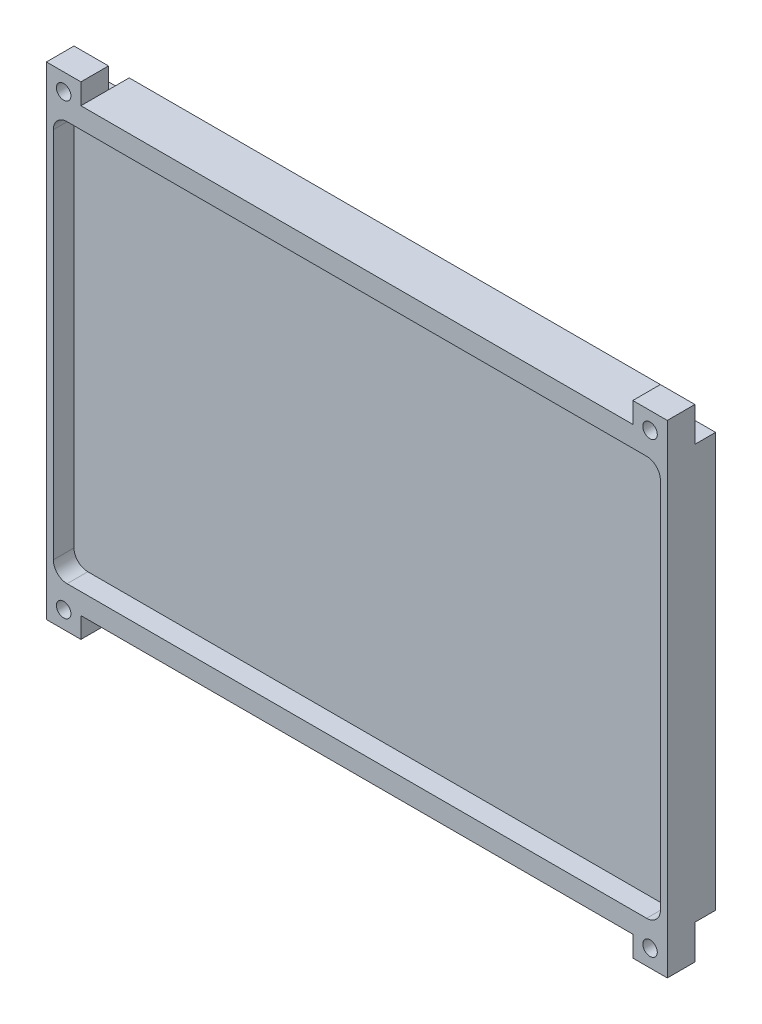
from build123d import *

# Parameters (mm, degrees)
SKETCH_1_W           = 100
SKETCH_1_H           = 70
EXTRUDE_1_DEPTH      = 10
SKETCH_6_W           = 5
SKETCH_6_H           = 5
CUT_EXTRUDE_4_DEPTH  = 5
SKETCH_7_W           = 5
SKETCH_7_H           = 5
CUT_EXTRUDE_5_DEPTH  = 3
SKETCH_8_R           = 1.05
CUT_EXTRUDE_6_DEPTH  = 42
SKETCH_10_W          = 100
SKETCH_10_H          = 70
CUT_EXTRUDE_7_DEPTH  = 3
SKETCH_11_W          = 7
SKETCH_11_H          = 70
CUT_EXTRUDE_8_DEPTH  = 5
SKETCH_12_W          = 7
SKETCH_12_H          = 70
CUT_EXTRUDE_9_DEPTH  = 5
SKETCH_15_W          = 82
SKETCH_15_H          = 52
CUT_EXTRUDE_12_DEPTH = 3
SKETCH_16_W          = 5
SKETCH_16_H          = 5
SKETCH_16_R          = 1.05
EXTRUDE_2_DEPTH      = 5
SKETCH_18_W          = 80
SKETCH_18_H          = 3
CUT_EXTRUDE_13_DEPTH = 10
SKETCH_19_W          = 82
SKETCH_19_H          = 52
CUT_EXTRUDE_14_DEPTH = 3
SKETCH_20_W          = 5
SKETCH_20_H          = 5
CUT_EXTRUDE_15_DEPTH = 3


with BuildPart() as part:
    # 草圖1 → 填料-伸長1 (new body)
    with BuildSketch(Plane.XY):
        with Locations((-39.08671555, 7.98136646)):
            Rectangle(SKETCH_1_W, SKETCH_1_H)
    extrude(amount=EXTRUDE_1_DEPTH)

    # 草圖6 → 除料-伸長4 (cut)
    with BuildSketch(Plane.XY.offset(10)):
        with Locations((3.41328445, 40.48136646)):
            Rectangle(SKETCH_6_W, SKETCH_6_H)
        with Locations((-81.58671555, 40.48136646)):
            Rectangle(SKETCH_6_W, SKETCH_6_H)
        with Locations((-81.58671555, -24.51863354)):
            Rectangle(SKETCH_6_W, SKETCH_6_H)
        with Locations((3.41328445, -24.51863354)):
            Rectangle(SKETCH_6_W, SKETCH_6_H)
    extrude(amount=-CUT_EXTRUDE_4_DEPTH, mode=Mode.SUBTRACT)

    # 草圖7 → 除料-伸長5 (cut)
    with BuildSketch(Plane(origin=(0, 0, 0), x_dir=(-1, 0, 0), z_dir=(0, 0, -1))):
        with Locations((81.58671555, 40.48136646)):
            Rectangle(SKETCH_7_W, SKETCH_7_H)
        with Locations((-3.41328445, 40.48136646)):
            Rectangle(SKETCH_7_W, SKETCH_7_H)
        with Locations((81.58671555, -24.51863354)):
            Rectangle(SKETCH_7_W, SKETCH_7_H)
        with Locations((-3.41328445, -24.51863354)):
            Rectangle(SKETCH_7_W, SKETCH_7_H)
    extrude(amount=-CUT_EXTRUDE_5_DEPTH, mode=Mode.SUBTRACT)

    # 草圖8 → 除料-伸長6 (cut)
    with BuildSketch(Plane(origin=(0, 0, 0), x_dir=(-1, 0, 0), z_dir=(0, 0, -1))):
        with Locations((-3.41328445, 40.48136646)):
            Circle(SKETCH_8_R)
        with Locations((81.58671555, 40.48136646)):
            Circle(SKETCH_8_R)
        with Locations((81.58671555, -24.51863354)):
            Circle(SKETCH_8_R)
        with Locations((-3.41328445, -24.51863354)):
            Circle(SKETCH_8_R)
    extrude(amount=-CUT_EXTRUDE_6_DEPTH, mode=Mode.SUBTRACT)

    # 草圖10 → 除料-伸長7 (cut)
    with BuildSketch(Plane.XY):
        with Locations((-39.08671555, 7.98136646)):
            Rectangle(SKETCH_10_W, SKETCH_10_H)
    extrude(amount=CUT_EXTRUDE_7_DEPTH, mode=Mode.SUBTRACT)

    # 草圖11 → 除料-伸長8 (cut)
    with BuildSketch(Plane(origin=(10.91328445, 0, 0), x_dir=(0, 0, -1), z_dir=(1, 0, 0))):
        with Locations((-6.5, 7.98136646)):
            Rectangle(SKETCH_11_W, SKETCH_11_H)
    extrude(amount=-CUT_EXTRUDE_8_DEPTH, mode=Mode.SUBTRACT)

    # 草圖12 → 除料-伸長9 (cut)
    with BuildSketch(Plane.ZY.offset(89.08671555)):
        with Locations((6.5, 7.98136646)):
            Rectangle(SKETCH_12_W, SKETCH_12_H)
    extrude(amount=-CUT_EXTRUDE_9_DEPTH, mode=Mode.SUBTRACT)

    # 草圖15 → 除料-伸長12 (cut)
    with BuildSketch(Plane.XY.offset(10)):
        with BuildLine():
            Line((-83.08671555, 34.98136646), (-83.08671555, -19.01863354))
            ThreePointArc((-83.08671555, -19.01863354), (-82.500929112, -20.432847103), (-81.08671555, -21.01863354))
            Line((-81.08671555, -21.01863354), (2.91328445, -21.01863354))
            ThreePointArc((2.91328445, -21.01863354), (4.327498013, -20.432847103), (4.91328445, -19.01863354))
            Line((4.91328445, -19.01863354), (4.91328445, 34.98136646))
            ThreePointArc((4.91328445, 34.98136646), (4.327498013, 36.395580022), (2.91328445, 36.98136646))
            Line((2.91328445, 36.98136646), (-81.08671555, 36.98136646))
            ThreePointArc((-81.08671555, 36.98136646), (-82.500929112, 36.395580022), (-83.08671555, 34.98136646))
        make_face()
        with Locations((-39.08671555, 7.98136646)):
            Rectangle(SKETCH_15_W, SKETCH_15_H, mode=Mode.SUBTRACT)
    extrude(amount=-CUT_EXTRUDE_12_DEPTH, mode=Mode.SUBTRACT)

    # 草圖16 → 填料-伸長2 (add)
    with BuildSketch(Plane.XY.offset(5)):
        with Locations((-81.58671555, 40.48136646)):
            Rectangle(SKETCH_16_W, SKETCH_16_H)
        with Locations((-81.58671555, 40.48136646)):
            Circle(SKETCH_16_R, mode=Mode.SUBTRACT)
        with Locations((3.41328445, 40.48136646)):
            Rectangle(SKETCH_16_W, SKETCH_16_H)
        with Locations((3.41328445, 40.48136646)):
            Circle(SKETCH_16_R, mode=Mode.SUBTRACT)
        with Locations((3.41328445, -24.51863354)):
            Rectangle(SKETCH_16_W, SKETCH_16_H)
        with Locations((3.41328445, -24.51863354)):
            Circle(SKETCH_16_R, mode=Mode.SUBTRACT)
        with Locations((-81.58671555, -24.51863354)):
            Rectangle(SKETCH_16_W, SKETCH_16_H)
        with Locations((-81.58671555, -24.51863354)):
            Circle(SKETCH_16_R, mode=Mode.SUBTRACT)
    extrude(amount=EXTRUDE_2_DEPTH)

    # 草圖18 → 除料-伸長13 (cut)
    with BuildSketch(Plane.XY.offset(10)):
        with Locations((-39.08671555, 41.48136646)):
            Rectangle(SKETCH_18_W, SKETCH_18_H)
        with Locations((-39.08671555, -25.51863354)):
            Rectangle(SKETCH_18_W, SKETCH_18_H)
    extrude(amount=-CUT_EXTRUDE_13_DEPTH, mode=Mode.SUBTRACT)

    # 草圖19 → 除料-伸長14 (cut)
    with BuildSketch(Plane.XY.offset(10)):
        with Locations((-39.08671555, 7.98136646)):
            Rectangle(SKETCH_19_W, SKETCH_19_H)
    extrude(amount=-CUT_EXTRUDE_14_DEPTH, mode=Mode.SUBTRACT)

    # 草圖20 → 除料-伸長15 (cut)
    with BuildSketch(Plane(origin=(0, 0, 3), x_dir=(-1, 0, 0), z_dir=(0, 0, -1))):
        with Locations((81.58671555, 40.48136646)):
            Rectangle(SKETCH_20_W, SKETCH_20_H)
        with Locations((-3.41328445, 40.48136646)):
            Rectangle(SKETCH_20_W, SKETCH_20_H)
        with Locations((81.58671555, -24.51863354)):
            Rectangle(SKETCH_20_W, SKETCH_20_H)
        with Locations((-3.41328445, -24.51863354)):
            Rectangle(SKETCH_20_W, SKETCH_20_H)
    extrude(amount=-CUT_EXTRUDE_15_DEPTH, mode=Mode.SUBTRACT)


solid = part.part
